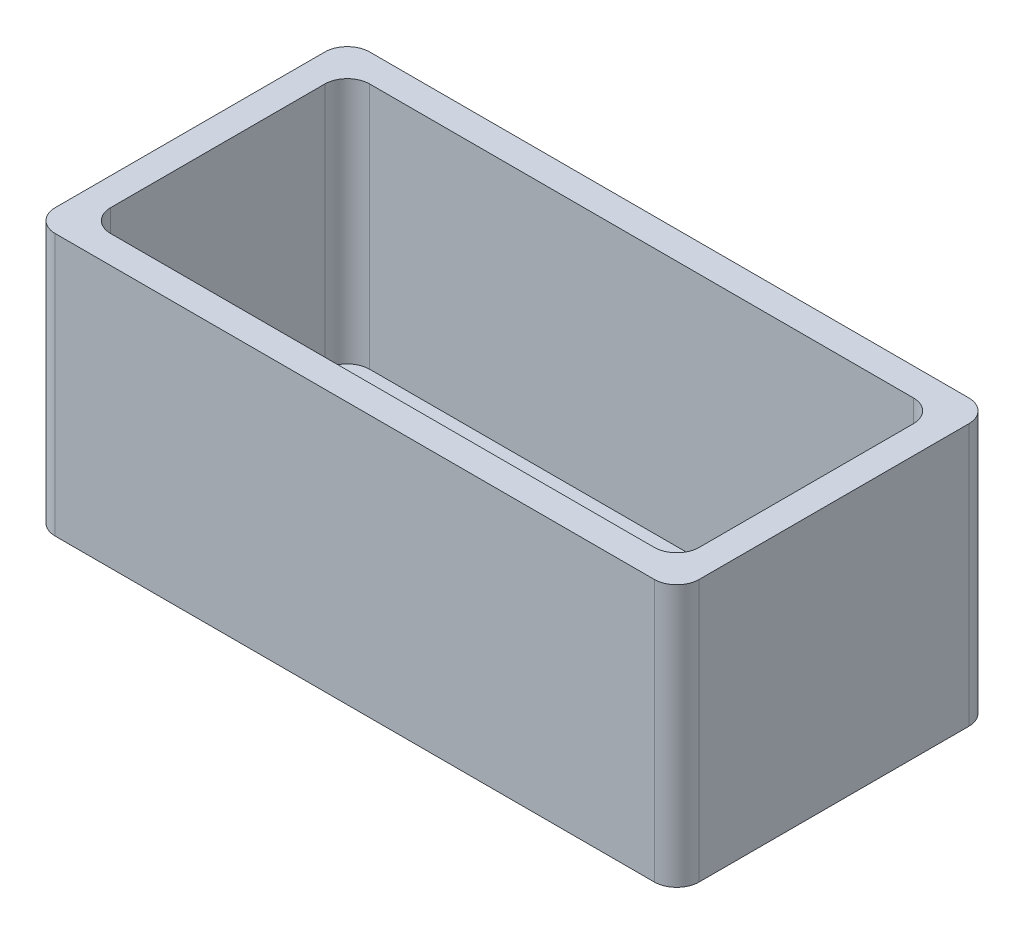
from build123d import *

# Parameters (mm, degrees)
SKETCH1_W           = 86
SKETCH1_H           = 42
SKETCH1_R           = 1.5
BOSS_EXTRUDE1_DEPTH = 35
FILLET1_R           = 3
CUT_EXTRUDE1_DEPTH  = 33


with BuildPart() as part:
    # Sketch1 → Boss-Extrude1 (new body)
    with BuildSketch(Plane(origin=(0, 0, 0), x_dir=(1, 0, 0), z_dir=(0, 1, 0))):
        with Locations((43, 21)):
            Rectangle(SKETCH1_W, SKETCH1_H)
        with Locations((9, 10)):
            Circle(SKETCH1_R, mode=Mode.SUBTRACT)
        with Locations((77, 10)):
            Circle(SKETCH1_R, mode=Mode.SUBTRACT)
    extrude(amount=BOSS_EXTRUDE1_DEPTH)

    # Fillet1
    fillet1_edges = [part.edges().sort_by_distance(p)[0] for p in [
        (0, 17.5, -42),
        (86, 17.5, -42),
        (86, 17.5, 0),
        (0, 17.5, 0),
    ]]
    fillet(fillet1_edges, radius=FILLET1_R)

    # Sketch2 → Cut-Extrude1 (cut)
    with BuildSketch(Plane(origin=(0, 35, 0), x_dir=(1, 0, 0), z_dir=(0, 1, 0))):
        with BuildLine():
            Line((6.7, 3.7), (79.3, 3.7))
            ThreePointArc((79.3, 3.7), (81.421320344, 4.578679656), (82.3, 6.7))
            Line((82.3, 6.7), (82.3, 35.3))
            ThreePointArc((82.3, 35.3), (81.421320344, 37.421320344), (79.3, 38.3))
            Line((79.3, 38.3), (6.7, 38.3))
            ThreePointArc((6.7, 38.3), (4.578679656, 37.421320344), (3.7, 35.3))
            Line((3.7, 35.3), (3.7, 6.7))
            ThreePointArc((3.7, 6.7), (4.578679656, 4.578679656), (6.7, 3.7))
        make_face()
    extrude(amount=-CUT_EXTRUDE1_DEPTH, mode=Mode.SUBTRACT)


solid = part.part
